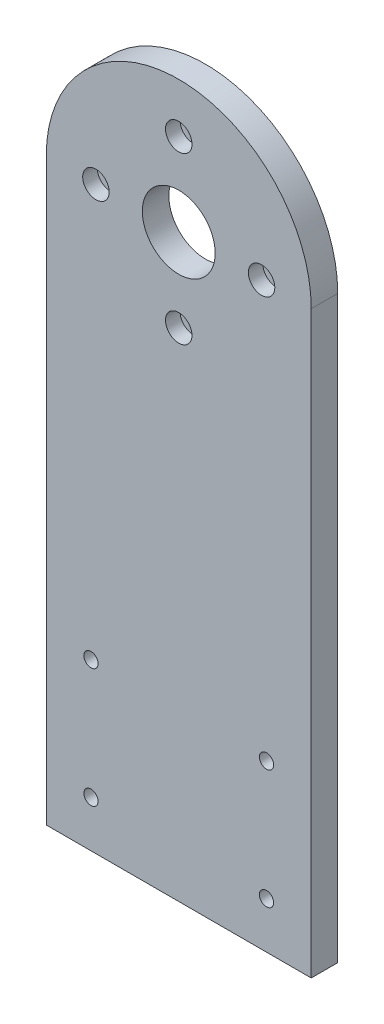
from build123d import *

# Parameters (mm, degrees)
SKETCH1_R                                           = 8
BOSS_EXTRUDE1_DEPTH                                 = 8
CBORE_FOR_M4_HEX_SOCKET_HEAD_CAP_SCREW2_D           = 4.3
CBORE_FOR_M4_HEX_SOCKET_HEAD_CAP_SCREW2_CBORE_D     = 8
CBORE_FOR_M4_HEX_SOCKET_HEAD_CAP_SCREW2_CBORE_DEPTH = 4.4
F_20_0MM_TRANSITIONAL_DOWEL_HOLE1_D                 = 22
M4_CLEARANCE_HOLE2_D                                = 4.3


with BuildPart() as part:
    # Sketch1 → Boss-Extrude1 (new body)
    with BuildSketch(Plane.XY):
        with BuildLine():
            Line((0, 0), (-80, 0))
            Line((-80, 0), (-80, 175))
            ThreePointArc((-80, 175), (-40, 215), (0, 175))
            Line((0, 175), (0, 0))
        make_face()
        with Locations((-40, 175)):
            Circle(SKETCH1_R, mode=Mode.SUBTRACT)
    extrude(amount=BOSS_EXTRUDE1_DEPTH)

    # CBORE for M4 Hex Socket Head Cap Screw2 (through all)
    with Locations(Plane.XY.offset(8)):
        with Locations((-40, 200), (-15, 175), (-40, 150), (-65, 175)):
            CounterBoreHole(CBORE_FOR_M4_HEX_SOCKET_HEAD_CAP_SCREW2_D / 2, CBORE_FOR_M4_HEX_SOCKET_HEAD_CAP_SCREW2_CBORE_D / 2, CBORE_FOR_M4_HEX_SOCKET_HEAD_CAP_SCREW2_CBORE_DEPTH)

    # Ø20.0mm Transitional Dowel Hole1 (through all)
    with Locations(Plane.XY.offset(8)):
        with Locations((-40, 175)):
            Hole(F_20_0MM_TRANSITIONAL_DOWEL_HOLE1_D / 2)

    # M4 Clearance Hole2 (through all)
    with Locations(Plane.XY.offset(8)):
        with Locations((-66.5, 50), (-13.5, 14), (-66.5, 14), (-13.5, 50)):
            Hole(M4_CLEARANCE_HOLE2_D / 2)


solid = part.part
